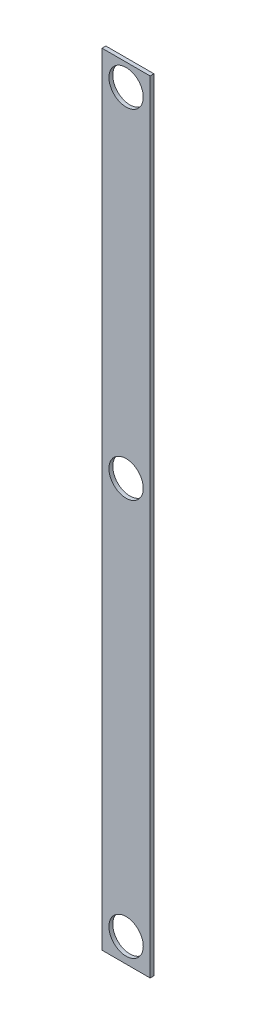
from build123d import *

# Parameters (mm, degrees)
SKETCH1_W           = 40
SKETCH1_H           = 650
BOSS_EXTRUDE1_DEPTH = 3.175
SKETCH2_R           = 14.279
CUT_EXTRUDE1_DEPTH  = 4.175


with BuildPart() as part:
    # Sketch1 → Boss-Extrude1 (new body)
    with BuildSketch(Plane.XY):
        with Locations((20, -325)):
            Rectangle(SKETCH1_W, SKETCH1_H)
    extrude(amount=BOSS_EXTRUDE1_DEPTH)

    # Sketch2 → Cut-Extrude1 (cut, through all)
    with BuildSketch(Plane.XY.offset(3.175)):
        with Locations((20, -18.141364063)):
            Circle(SKETCH2_R)
        with Locations((20, -630)):
            Circle(SKETCH2_R)
        with Locations((20, -300)):
            Circle(SKETCH2_R)
    extrude(amount=-CUT_EXTRUDE1_DEPTH, mode=Mode.SUBTRACT)


solid = part.part
